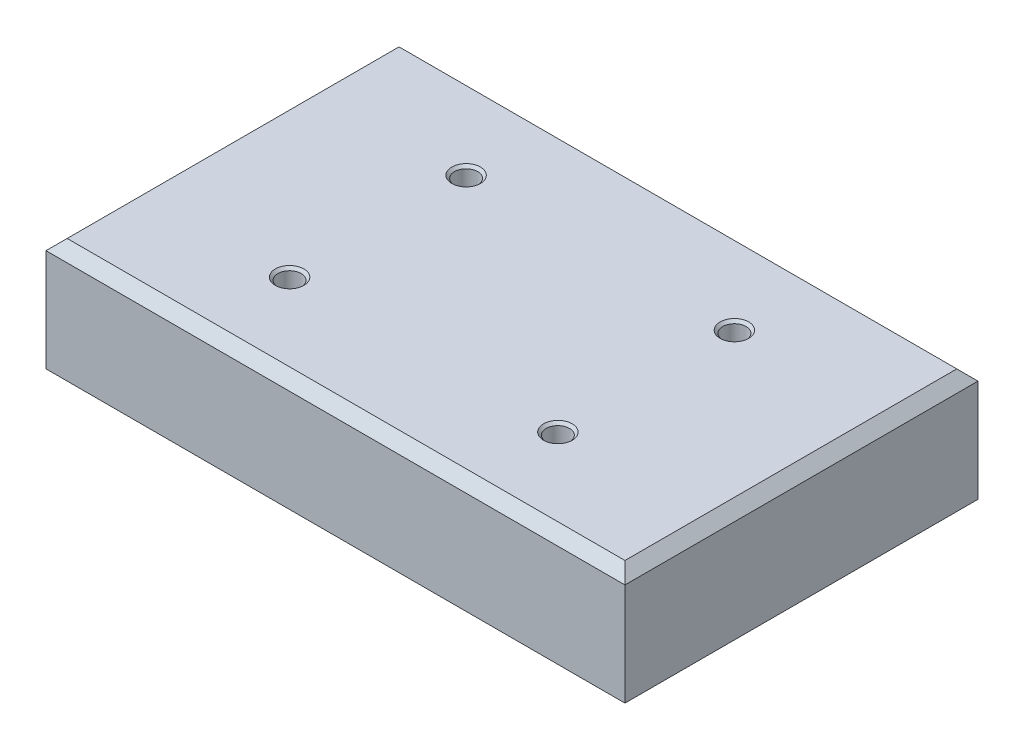
from build123d import *

# Parameters (mm, degrees)
SKETCH_1_W                  = 82
SKETCH_1_H                  = 50
EXTRUDE_1_DEPTH             = 16
CHAMFER_1_SIZE              = 1.5
HOLE_WIZARD_M41_D           = 3.3
HOLE_WIZARD_M41_DEPTH       = 7.008579979
HOLE_WIZARD_M41_CSINK_D     = 4.05
HOLE_WIZARD_M41_CSINK_ANGLE = 90
HOLE_WIZARD_M41_TIP         = 0.991420021


with BuildPart() as part:
    # Эскиз1 → Бобышка-Вытянуть1 (new body)
    with BuildSketch(Plane(origin=(0, 0, 0), x_dir=(1, 0, 0), z_dir=(0, 1, 0))):
        with Locations((41, 25)):
            Rectangle(SKETCH_1_W, SKETCH_1_H)
    extrude(amount=EXTRUDE_1_DEPTH)

    # Фаска1
    chamfer_1_edges = [part.edges().sort_by_distance(p)[0] for p in [
        (82, 16, -25),
        (41, 16, -50),
        (0, 16, -25),
        (41, 16, 0),
    ]]
    chamfer(chamfer_1_edges, length=CHAMFER_1_SIZE)

    # Отверстие обработанное метчиком M41
    with Locations(Plane(origin=(22, 16, -37.5), x_dir=(0, 0, 1), z_dir=(0, 1, 0))):
        with Locations((0, 0), (25, 0), (0, 38), (25, 38)):
            CounterSinkHole(HOLE_WIZARD_M41_D / 2, HOLE_WIZARD_M41_CSINK_D / 2, depth=HOLE_WIZARD_M41_DEPTH, counter_sink_angle=HOLE_WIZARD_M41_CSINK_ANGLE)
            with Locations((0, 0, -(HOLE_WIZARD_M41_DEPTH + HOLE_WIZARD_M41_TIP / 2))):  # 118° drill point
                Cone(0, HOLE_WIZARD_M41_D / 2, HOLE_WIZARD_M41_TIP, mode=Mode.SUBTRACT)


solid = part.part
